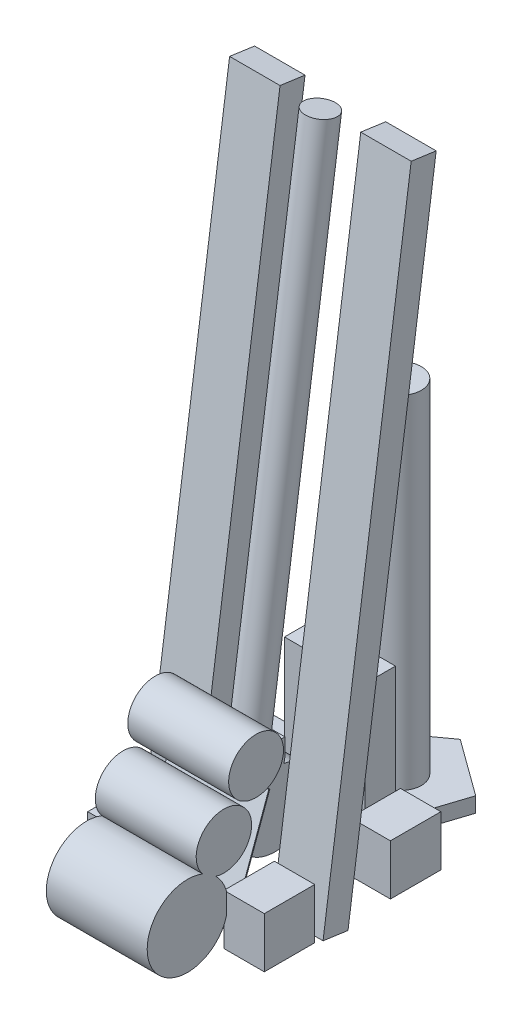
from build123d import *

# Parameters (mm, degrees)
SKETCH1_W           = 101.6
SKETCH1_H           = 127
DRIVETRAIN_DEPTH    = 127
DRIVETRAIN_2_DEPTH  = 127
DRIVETRAIN_3_DEPTH  = 127
DRIVETRAIN_4_DEPTH  = 127
BOSS_EXTRUDE2_DEPTH = 38.1
SKETCH4_R           = 51.816
BOSS_EXTRUDE3_DEPTH = 861.822
BOSS_EXTRUDE4_DEPTH = 25.4
SKETCH7_W           = 1320.998239158
SKETCH7_H           = 38.1
BOSS_EXTRUDE5_DEPTH = 241.3
SKETCH12_R          = 101.6
SKETCH12_R_2        = 69.760716059
SKETCH12_R_3        = 69.014032316
BOSS_EXTRUDE8_DEPTH = 127
SKETCH9_W           = 1604.28012948
SKETCH9_H           = 127
LIFT_DEPTH          = 63.5
LIFT_2_DEPTH        = 63.5
SKETCH10_W          = 203.2
SKETCH10_H          = 76.2
GOAL_LIFT_DEPTH     = 381


with BuildPart() as part:
    # Sketch1 → Drivetrain (new body)
    with BuildSketch(Plane(origin=(0, 0, 0), x_dir=(1, 0, 0), z_dir=(0, 1, 0))):
        with Locations((-171.45, -158.75)):
            Rectangle(SKETCH1_W, SKETCH1_H)
    extrude(amount=DRIVETRAIN_DEPTH)


with BuildPart() as body_2:
    # Sketch1 → Drivetrain 2 (new body)
    with BuildSketch(Plane(origin=(0, 0, 0), x_dir=(1, 0, 0), z_dir=(0, 1, 0))):
        with Locations((171.45, -158.75)):
            Rectangle(SKETCH1_W, SKETCH1_H)
    extrude(amount=DRIVETRAIN_2_DEPTH)


with BuildPart() as body_3:
    # Sketch1 → Drivetrain 3 (new body)
    with BuildSketch(Plane(origin=(0, 0, 0), x_dir=(1, 0, 0), z_dir=(0, 1, 0))):
        with Locations((171.45, 158.75)):
            Rectangle(SKETCH1_W, SKETCH1_H)
    extrude(amount=DRIVETRAIN_3_DEPTH)


with BuildPart() as body_4:
    # Sketch1 → Drivetrain 4 (new body)
    with BuildSketch(Plane(origin=(0, 0, 0), x_dir=(1, 0, 0), z_dir=(0, 1, 0))):
        with Locations((-171.45, 158.75)):
            Rectangle(SKETCH1_W, SKETCH1_H)
    extrude(amount=DRIVETRAIN_4_DEPTH)


with BuildPart() as body_5:
    # Sketch3 → Boss-Extrude2 (new body)
    with BuildSketch(Plane(origin=(0, 0, 0), x_dir=(1, 0, 0), z_dir=(0, 1, 0))):
        Polygon((-88.059086234, 222.25), (88.059086234, 222.25), (142.482594544, 389.748335563), (0, 493.268), (-142.482594544, 389.748335563), align=None)
    extrude(amount=BOSS_EXTRUDE2_DEPTH)

    # Sketch4 → Boss-Extrude3 (add)
    with BuildSketch(Plane(origin=(0, 38.1, 0), x_dir=(1, 0, 0), z_dir=(0, 1, 0))):
        with Locations(Location((0, 343.452934225, 0), (0, 0, 270))):
            Circle(SKETCH4_R)
    extrude(amount=BOSS_EXTRUDE3_DEPTH)


with BuildPart() as body_6:
    # Sketch5 → Boss-Extrude4 (new, symmetric)
    with BuildSketch(Plane(origin=(0, 0, 0), x_dir=(0, 0, -1), z_dir=(1, 0, 0))):
        with BuildLine():
            Line((26.436715133, 289.693154062), (-106.913284867, 289.693154062))
            Line((-106.913284867, 289.693154062), (-106.913284867, 179.431240311))
            add(Edge.make_bspline(
                [(-106.913284867, 179.431240311), (-106.922275514, 177.314085183), (-106.844714825, 173.100022171), (-106.31155836, 164.517909306), (-104.937916384, 153.66518019), (-102.147116697, 140.558434457), (-96.860695677, 123.207488958), (-89.140150055, 106.380193996), (-78.695792066, 90.878883106), (-69.408123184, 80.167132386), (-60.386249114, 72.245634114), (-52.39130403, 66.691297247), (-45.99151885, 62.954859956), (-39.278923957, 59.736475089), (-30.06602637, 56.16180659), (-18.118136003, 52.977720447), (-3.39072609, 51.139329122), (11.470537994, 51.257526659), (26.208790933, 53.358691633), (40.552465987, 57.527924547), (54.195009809, 63.874750123), (66.720940218, 72.636610137), (77.279681687, 83.231040861), (85.929191733, 95.271807521), (92.611384836, 108.432594601), (97.298063179, 122.436261075), (99.919873761, 137.026968228), (100.385639212, 151.895462865), (98.543779565, 166.759173971), (94.887371789, 178.859467795), (90.553070433, 188.137455125), (85.218361014, 197.037872982), (77.080983632, 206.845723087), (65.529417153, 216.561483785), (52.63591563, 224.204406044), (38.758572394, 229.748850977), (29.019813004, 231.986328043), (24.102701524, 232.707697092)],
                knots=[0.074418032, 0.074418032, 0.074418032, 0.074418032, 0.088878632, 0.103339233, 0.132260434, 0.161181635, 0.190102836, 0.247945239, 0.27686644, 0.305787641, 0.334708842, 0.349169443, 0.363630043, 0.378090644, 0.392551244, 0.421472445, 0.450393647, 0.479314848, 0.508236049, 0.53715725, 0.566078451, 0.594999652, 0.623920853, 0.652842055, 0.681763256, 0.710684457, 0.739605658, 0.768526859, 0.79744806, 0.826369261, 0.840829862, 0.855290463, 0.884211664, 0.913132865, 0.942054066, 0.970975267, 0.999896468, 0.999896468, 0.999896468, 0.999896468], degree=3))
            add(Edge.make_bspline(
                [(24.102701524, 232.707697092), (24.382820632, 233.837593719), (24.896858704, 236.10272623), (25.436705696, 238.986704891), (25.806838001, 241.318987531), (26.012617854, 242.784257474), (26.163008004, 243.969909968), (26.249075931, 244.697044834), (26.318182296, 245.318086319), (26.370408001, 245.802218308), (26.410286896, 246.168265776), (26.436715133, 246.411642205)],
                knots=[-0.022894974, -0.022894974, -0.022894974, -0.022894974, 0.042322725, 0.107540425, 0.140149275, 0.172758125, 0.18906255, 0.205366975, 0.213519187, 0.2216714, 0.237975825, 0.237975825, 0.237975825, 0.237975825], degree=3))
            Line((26.436715133, 246.411642205), (26.436715133, 289.693154062))
        make_face()
    extrude(amount=BOSS_EXTRUDE4_DEPTH, both=True)

    # Sketch7 → Revolve1 (revolve)
    with BuildSketch(Plane(origin=(0, 11.056920966, 79.158440361), x_dir=(0, 0.9903850942141906, -0.13833786595993453), z_dir=(0, -0.13833786595993453, -0.9903850942141906)), mode=Mode.PRIVATE) as revolve1_sk:
        with Locations((932.616745586, 19.05)):
            Rectangle(SKETCH7_W, SKETCH7_H)
    revolve(revolve1_sk.sketch.rotate(Axis((0, 1588.855127182, -141.229808653), (0, -0.9903850942141906, 0.1383378659599345)), 90), axis=Axis((0, 1588.855127182, -141.229808653), (0, -0.9903850942141906, 0.1383378659599345)))


with BuildPart() as body_7:
    # Sketch8 → Boss-Extrude5 (new body)
    with BuildSketch(Plane(origin=(-120.65, 0, 0), x_dir=(0, 0, -1), z_dir=(1, 0, 0))):
        with BuildLine():
            Line((-106.913284867, 289.693154062), (-187.876482837, 67.248595832))
            ThreePointArc((-187.876482837, 67.248595832), (-201.26884186, 49.795333751), (-222.25, 43.18))
            Line((-222.25, 43.18), (-222.25, 45.72))
            ThreePointArc((-222.25, 45.72), (-202.725726009, 51.875979943), (-190.263302094, 68.117326996))
            Line((-190.263302094, 68.117326996), (-109.300104124, 290.561885226))
            Line((-109.300104124, 290.561885226), (-106.913284867, 289.693154062))
        make_face()
    extrude(amount=BOSS_EXTRUDE5_DEPTH)


with BuildPart() as body_8:
    # Sketch12 → Boss-Extrude8 (new, symmetric)
    with BuildSketch(Plane(origin=(0, 0, 0), x_dir=(0, 0, -1), z_dir=(1, 0, 0))):
        with Locations((-320.257176019, 101.6)):
            Circle(SKETCH12_R)
        with Locations((-228.726819478, 240.868027394)):
            Circle(SKETCH12_R_2)
        with Locations((-147.71567639, 364.130544019)):
            Circle(SKETCH12_R_3)
    extrude(amount=BOSS_EXTRUDE8_DEPTH, both=True)


with BuildPart() as body_9:
    # Sketch9 → Lift (new body)
    with BuildSketch(Plane(origin=(0, 11.056920966, 79.158440361), x_dir=(0, 0.9903850942141906, -0.13833786595993453), z_dir=(0, -0.13833786595993453, -0.9903850942141906))):
        with Locations((790.975800425, 165.1)):
            Rectangle(SKETCH9_W, SKETCH9_H)
    extrude(amount=LIFT_DEPTH)


with BuildPart() as body_10:
    # Sketch9 → Lift 2 (new body)
    with BuildSketch(Plane(origin=(0, 11.056920966, 79.158440361), x_dir=(0, 0.9903850942141906, -0.13833786595993453), z_dir=(0, -0.13833786595993453, -0.9903850942141906))):
        with Locations((790.975800425, -165.1)):
            Rectangle(SKETCH9_W, SKETCH9_H)
    extrude(amount=LIFT_2_DEPTH)


with BuildPart() as body_11:
    # Sketch10 → Goal Lift (new body)
    with BuildSketch(Plane(origin=(0, 0, 0), x_dir=(1, 0, 0), z_dir=(0, 1, 0))):
        with Locations((0, 190.5)):
            Rectangle(SKETCH10_W, SKETCH10_H)
    extrude(amount=GOAL_LIFT_DEPTH)


solid = Compound([part.part, body_2.part, body_3.part, body_4.part, body_5.part, body_6.part, body_7.part, body_8.part, body_9.part, body_10.part, body_11.part])
